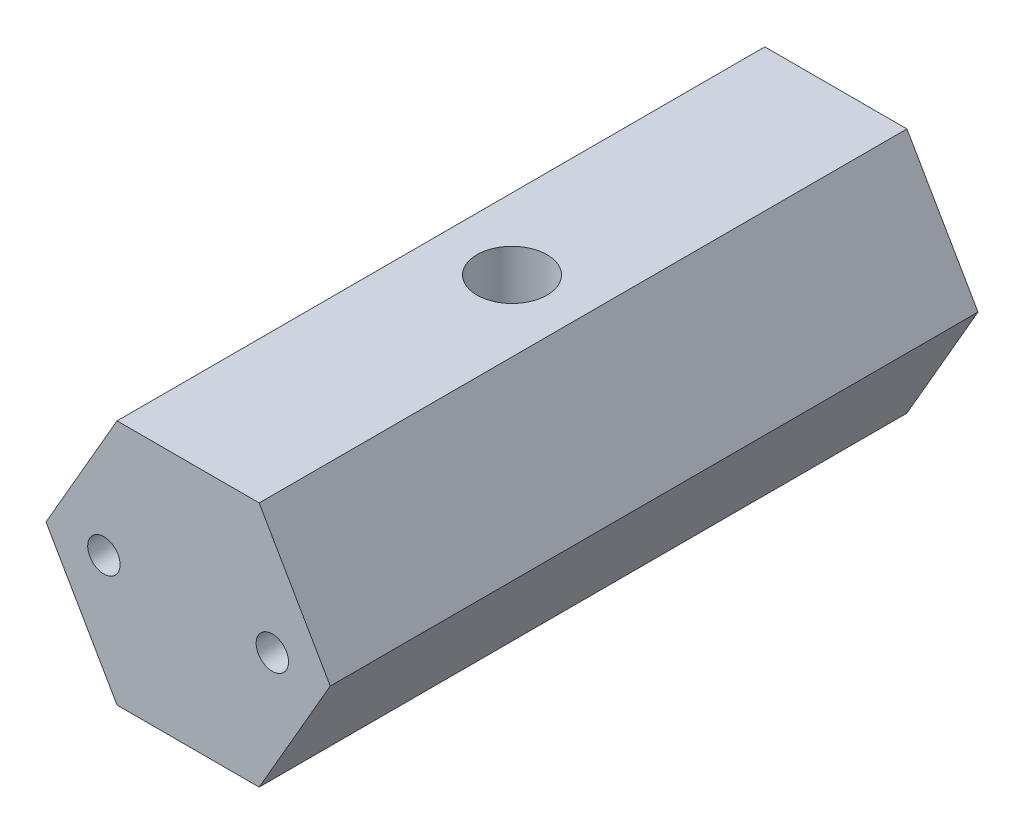
from build123d import *

# Parameters (mm, degrees)
SKETCH1_R                   = 1.25
BOSS_EXTRUDE1_DEPTH         = 25
F_1_4_28_TAPPED_HOLE1_D     = 5.4102
F_1_4_28_TAPPED_HOLE1_DEPTH = 19


with BuildPart() as part:
    # Sketch1 → Boss-Extrude1 (new body, symmetric)
    with BuildSketch(Plane.XY):
        Polygon((-5.484827557, -9.5), (5.484827557, -9.5), (10.969655115, 0), (5.484827557, 9.5), (-5.484827557, 9.5), (-10.969655115, 0), align=None)
        with Locations((-6.5, 0)):
            Circle(SKETCH1_R, mode=Mode.SUBTRACT)
        with Locations((6.5, 0)):
            Circle(SKETCH1_R, mode=Mode.SUBTRACT)
    extrude(amount=BOSS_EXTRUDE1_DEPTH, both=True)

    # 1/4-28 Tapped Hole1
    with Locations(Plane(origin=(0, 9.5, 0), x_dir=(1, 0, 0), z_dir=(0, 1, 0))):
        with Locations((0, 0)):
            Hole(F_1_4_28_TAPPED_HOLE1_D / 2, depth=F_1_4_28_TAPPED_HOLE1_DEPTH)


solid = part.part
